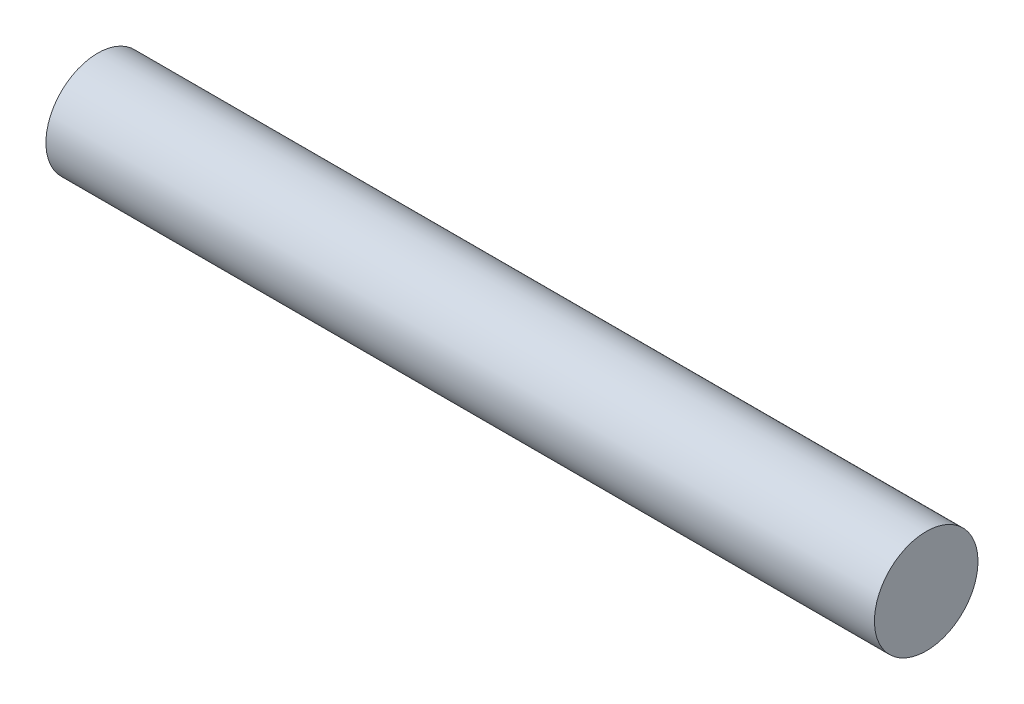
from build123d import *

# Parameters (mm, degrees)
SKETCH2_R           = 1
BOSS_EXTRUDE1_DEPTH = 16


with BuildPart() as part:
    # Sketch2 → Boss-Extrude1 (new body)
    with BuildSketch(Plane(origin=(0, 0, 0), x_dir=(0, 0, -1), z_dir=(1, 0, 0))):
        Circle(SKETCH2_R)
    extrude(amount=BOSS_EXTRUDE1_DEPTH)


solid = part.part
